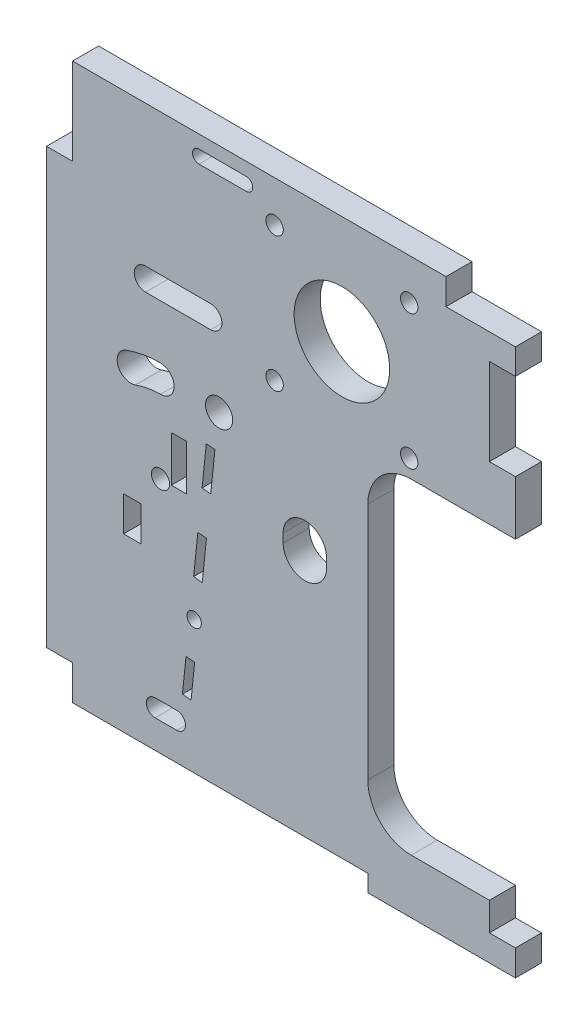
from build123d import *

# Parameters (mm, degrees)
ESQUISSE1_R        = 2
ESQUISSE1_R_2      = 11
ESQUISSE1_R_3      = 3.125
ESQUISSE1_R_4      = 2.1
ESQUISSE1_R_5      = 1.65
ESQUISSE1_W        = 4
ESQUISSE1_H        = 8
ESQUISSE1_W_2      = 3.5
ESQUISSE1_H_2      = 10.5
BOSS_EXTRU_1_DEPTH = 6


with BuildPart() as part:
    # Esquisse1 → Boss.-Extru.1 (new body)
    with BuildSketch(Plane.XY):
        with BuildLine():
            Line((2401.475943532, -52.104091931), (2401.475943532, -46.104091931))
            Line((2401.475943532, -46.104091931), (2395.475943532, -46.104091931))
            Line((2395.475943532, -46.104091931), (2395.475943532, -39.604091931))
            Line((2395.475943532, -39.604091931), (2377.475943532, -39.604091931))
            ThreePointArc((2377.475943532, -39.604091931), (2370.40487572, -36.675159743), (2367.475943532, -29.604091931))
            Line((2367.475943532, -29.604091931), (2367.475943532, 25.395908069))
            ThreePointArc((2367.475943532, 25.395908069), (2370.40487572, 32.466975881), (2377.475943532, 35.395908069))
            Line((2377.475943532, 35.395908069), (2397.475943532, 35.395908069))
            Line((2397.475943532, 35.395908069), (2401.475943532, 35.395908069))
            Line((2401.475943532, 35.395908069), (2401.475943532, 47.895908069))
            Line((2401.475943532, 47.895908069), (2395.475943532, 47.895908069))
            Line((2395.475943532, 47.895908069), (2395.475943532, 67.895908069))
            Line((2395.475943532, 67.895908069), (2401.475943532, 67.895908069))
            Line((2401.475943532, 67.895908069), (2401.475943532, 73.792808343))
            Line((2401.475943532, 73.792808343), (2395.475943532, 73.792808343))
            Line((2395.475943532, 73.792808343), (2385.475943532, 73.792808343))
            Line((2385.475943532, 73.792808343), (2385.475943532, 79.792808343))
            Line((2385.475943532, 79.792808343), (2299.475943532, 79.792808343))
            Line((2299.475943532, 79.792808343), (2299.475943532, 59.792808343))
            Line((2299.475943532, 59.792808343), (2293.475943532, 59.792808343))
            Line((2293.475943532, 59.792808343), (2293.475943532, -40.20719166))
            Line((2293.475943532, -40.20719166), (2299.475943532, -40.20719166))
            Line((2299.475943532, -40.20719166), (2299.475943532, -48.20719166))
            Line((2299.475943532, -48.20719166), (2367.475943532, -48.20719166))
            Line((2367.475943532, -48.20719166), (2367.475943532, -52.104091931))
            Line((2367.475943532, -52.104091931), (2401.475943532, -52.104091931))
        make_face()
        with Locations((2346.01021478, 70.349007801)):
            Circle(ESQUISSE1_R, mode=Mode.SUBTRACT)
        with Locations((2377.01021478, 70.349007801)):
            Circle(ESQUISSE1_R, mode=Mode.SUBTRACT)
        with Locations((2377.01021478, 39.349007801)):
            Circle(ESQUISSE1_R, mode=Mode.SUBTRACT)
        with Locations((2361.51021478, 54.849007801)):
            Circle(ESQUISSE1_R_2, mode=Mode.SUBTRACT)
        with Locations((2346.01021478, 39.349007801)):
            Circle(ESQUISSE1_R, mode=Mode.SUBTRACT)
        with Locations((2333.225943532, 26.564736553)):
            Circle(ESQUISSE1_R_3, mode=Mode.SUBTRACT)
        with Locations((2319.725943533, 6.564736553)):
            Circle(ESQUISSE1_R_4, mode=Mode.SUBTRACT)
        with Locations((2327.476078896, -17.594891177)):
            Circle(ESQUISSE1_R_5, mode=Mode.SUBTRACT)
        with BuildLine():
            Line((2331.275943532, 42.100855433), (2316.275943532, 42.100855433))
            ThreePointArc((2316.275943532, 42.100855433), (2313.675943532, 44.700855433), (2316.275943532, 47.300855433))
            Line((2316.275943532, 47.300855433), (2331.275943532, 47.300855433))
            ThreePointArc((2331.275943532, 47.300855433), (2333.875943532, 44.700855433), (2331.275943532, 42.100855433))
        make_face(mode=Mode.SUBTRACT)
        with BuildLine():
            Line((2347.975943532, 7.895908069), (2347.975943532, 9.895908069))
            ThreePointArc((2347.975943532, 9.895908069), (2352.975943532, 14.895908069), (2357.975943532, 9.895908069))
            Line((2357.975943532, 9.895908069), (2357.975943532, 7.895908069))
            ThreePointArc((2357.975943532, 7.895908069), (2352.975943532, 2.895908069), (2347.975943532, 7.895908069))
        make_face(mode=Mode.SUBTRACT)
        with BuildLine():
            Line((2339.47303261, 73.792808343), (2328.599494457, 73.792808343))
            ThreePointArc((2328.599494457, 73.792808343), (2327.099494457, 75.292808343), (2328.599494457, 76.792808343))
            Line((2328.599494457, 76.792808343), (2339.47303261, 76.792808343))
            ThreePointArc((2339.47303261, 76.792808343), (2340.97303261, 75.292808343), (2339.47303261, 73.792808343))
        make_face(mode=Mode.SUBTRACT)
        with Locations((2313.225943533, -4.641462904)):
            Rectangle(ESQUISSE1_W, ESQUISSE1_H, mode=Mode.SUBTRACT)
        Polygon((2329.302925864, 9.55284837), (2330.275943532, 18.879356423), (2332.265147216, 18.67182641), (2331.292129548, 9.345318358), align=None, mode=Mode.SUBTRACT)
        Polygon((2327.356890528, -9.100167734), (2328.329908196, 0.226340318), (2330.31911188, 0.018810306), (2329.346094212, -9.307697746), align=None, mode=Mode.SUBTRACT)
        Polygon((2324.775943532, -33.838899342), (2325.606063581, -25.882084609), (2327.595267264, -26.089614621), (2326.765147216, -34.046429354), align=None, mode=Mode.SUBTRACT)
        with Locations((2323.975943533, 11.814736553)):
            Rectangle(ESQUISSE1_W_2, ESQUISSE1_H_2, mode=Mode.SUBTRACT)
        with BuildLine():
            Line((2318.475943532, -37.70719166), (2323.475943532, -37.70719166))
            ThreePointArc((2323.475943532, -37.70719166), (2325.475943532, -39.70719166), (2323.475943532, -41.70719166))
            Line((2323.475943532, -41.70719166), (2318.475943532, -41.70719166))
            ThreePointArc((2318.475943532, -41.70719166), (2316.475943532, -39.70719166), (2318.475943532, -37.70719166))
        make_face(mode=Mode.SUBTRACT)
        with BuildLine():
            ThreePointArc((2319.725943533, 29.694736553), (2315.709461183, 29.34333988), (2311.815017618, 28.299826872))
            ThreePointArc((2311.815017618, 28.299826872), (2309.944302763, 24.28806592), (2313.956063715, 22.417351066))
            ThreePointArc((2313.956063715, 22.417351066), (2316.796498776, 23.178443347), (2319.725943533, 23.434736553))
            ThreePointArc((2319.725943533, 23.434736553), (2322.855943533, 26.564736553), (2319.725943533, 29.694736553))
        make_face(mode=Mode.SUBTRACT)
    extrude(amount=-BOSS_EXTRU_1_DEPTH)


solid = part.part
